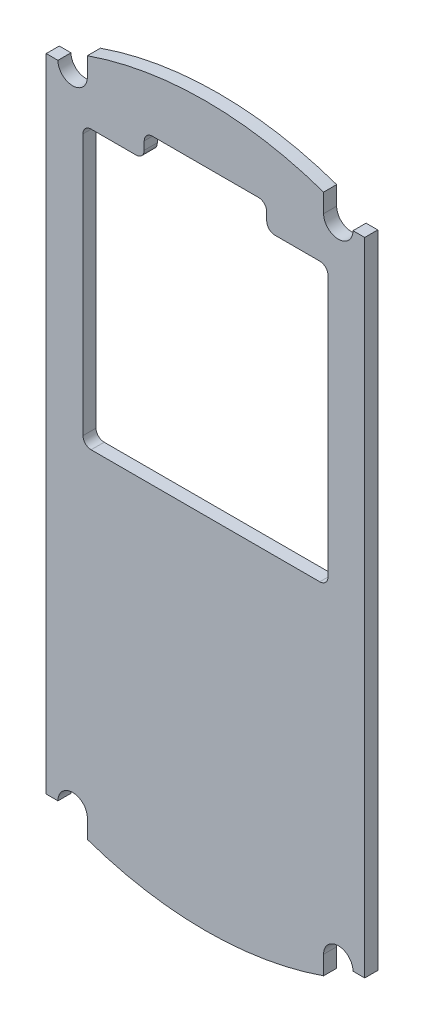
from build123d import *

# Parameters (mm, degrees)
EXTRUDE_1_DEPTH     = 1.6
CUT_EXTRUDE_1_DEPTH = 10
FILLET_2_R          = 1


with BuildPart() as part:
    # 草图1 → 凸台-拉伸1 (new body)
    with BuildSketch(Plane.XY):
        with BuildLine():
            Line((-19.5, 0), (-19.5, 39.264880132))
            Line((-19.5, 39.264880132), (-18.064045876, 39.264880132))
            ThreePointArc((-18.064045876, 39.264880132), (-16.264045876, 37.464880132), (-14.464045876, 39.264880132))
            Line((-14.464045876, 39.264880132), (-14.464045876, 41.554679362))
            ThreePointArc((-14.464045876, 41.554679362), (0, 44), (14.464045876, 41.554679362))
            Line((14.464045876, 41.554679362), (14.464045876, 39.264880132))
            ThreePointArc((14.464045876, 39.264880132), (16.264045876, 37.464880132), (18.064045876, 39.264880132))
            Line((18.064045876, 39.264880132), (19.5, 39.264880132))
            Line((19.5, 39.264880132), (19.5, 0))
            Line((19.5, 0), (19.5, -39.264880132))
            Line((19.5, -39.264880132), (18.064045876, -39.264880132))
            ThreePointArc((18.064045876, -39.264880132), (16.264045876, -37.464880132), (14.464045876, -39.264880132))
            Line((14.464045876, -39.264880132), (14.464045876, -41.554679362))
            ThreePointArc((14.464045876, -41.554679362), (0, -44), (-14.464045876, -41.554679362))
            Line((-14.464045876, -41.554679362), (-14.464045876, -39.264880132))
            ThreePointArc((-14.464045876, -39.264880132), (-16.264045876, -37.464880132), (-18.064045876, -39.264880132))
            Line((-18.064045876, -39.264880132), (-19.5, -39.264880132))
            Line((-19.5, -39.264880132), (-19.5, 0))
        make_face()
    extrude(amount=EXTRUDE_1_DEPTH)

    # 草图2 → 切除-拉伸1 (cut)
    with BuildSketch(Plane.XY.offset(1.6)):
        Polygon((-15, 0), (15, 0), (15, 34), (7.5, 34), (7.5, 37), (-7.5, 37), (-7.5, 34), (-15, 34), align=None)
    extrude(amount=-CUT_EXTRUDE_1_DEPTH, mode=Mode.SUBTRACT)

    # 圆角2
    fillet_2_edges = [part.edges().sort_by_distance(p)[0] for p in [
        (7.5, 37, 0.8),
        (7.5, 34, 0.8),
        (15, 34, 0.8),
        (15, 0, 0.8),
        (-15, 0, 0.8),
        (-15, 34, 0.8),
        (-7.5, 34, 0.8),
        (-7.5, 37, 0.8),
    ]]
    fillet(fillet_2_edges, radius=FILLET_2_R)


solid = part.part
